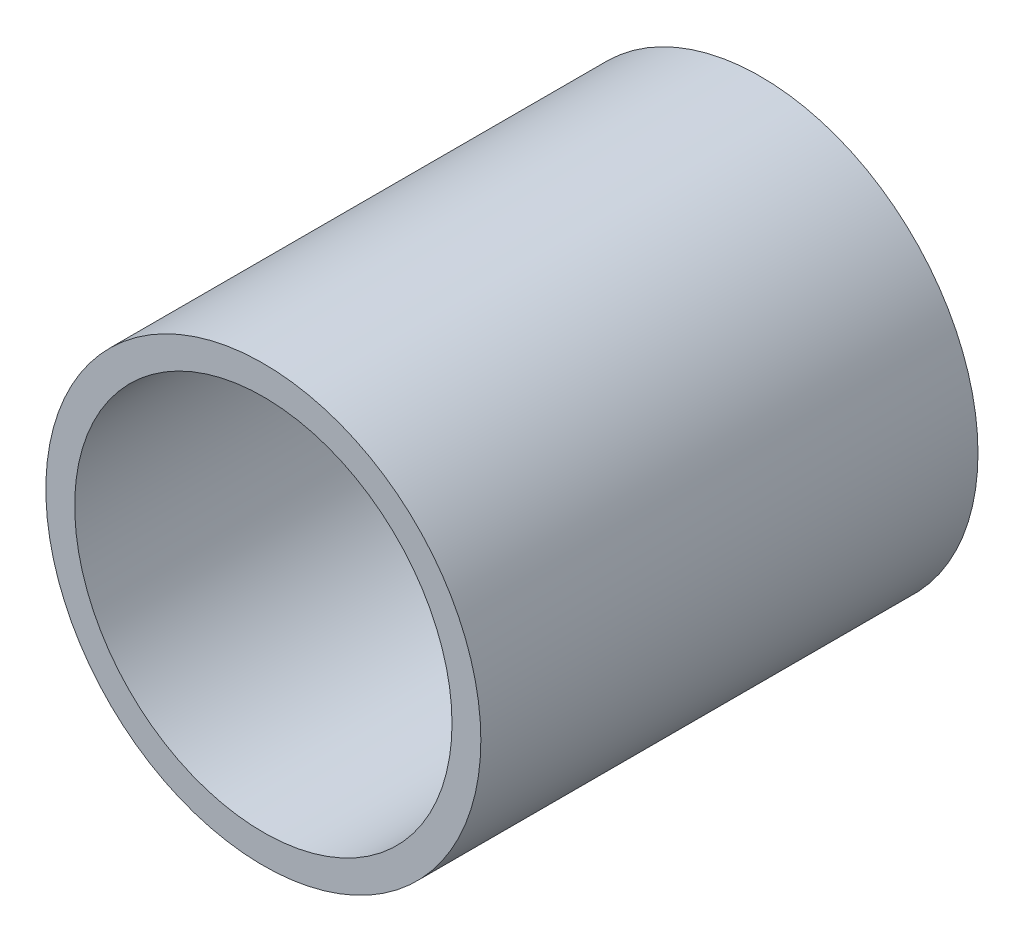
from build123d import *

# Parameters (mm, degrees)
SKETCH3_R           = 11.1125
SKETCH3_R_2         = 9.6393
BOSS_EXTRUDE1_DEPTH = 12.7


with BuildPart() as part:
    # Sketch3 → Boss-Extrude1 (new, symmetric)
    with BuildSketch(Plane.XY):
        Circle(SKETCH3_R)
        Circle(SKETCH3_R_2, mode=Mode.SUBTRACT)
    extrude(amount=BOSS_EXTRUDE1_DEPTH, both=True)


solid = part.part
